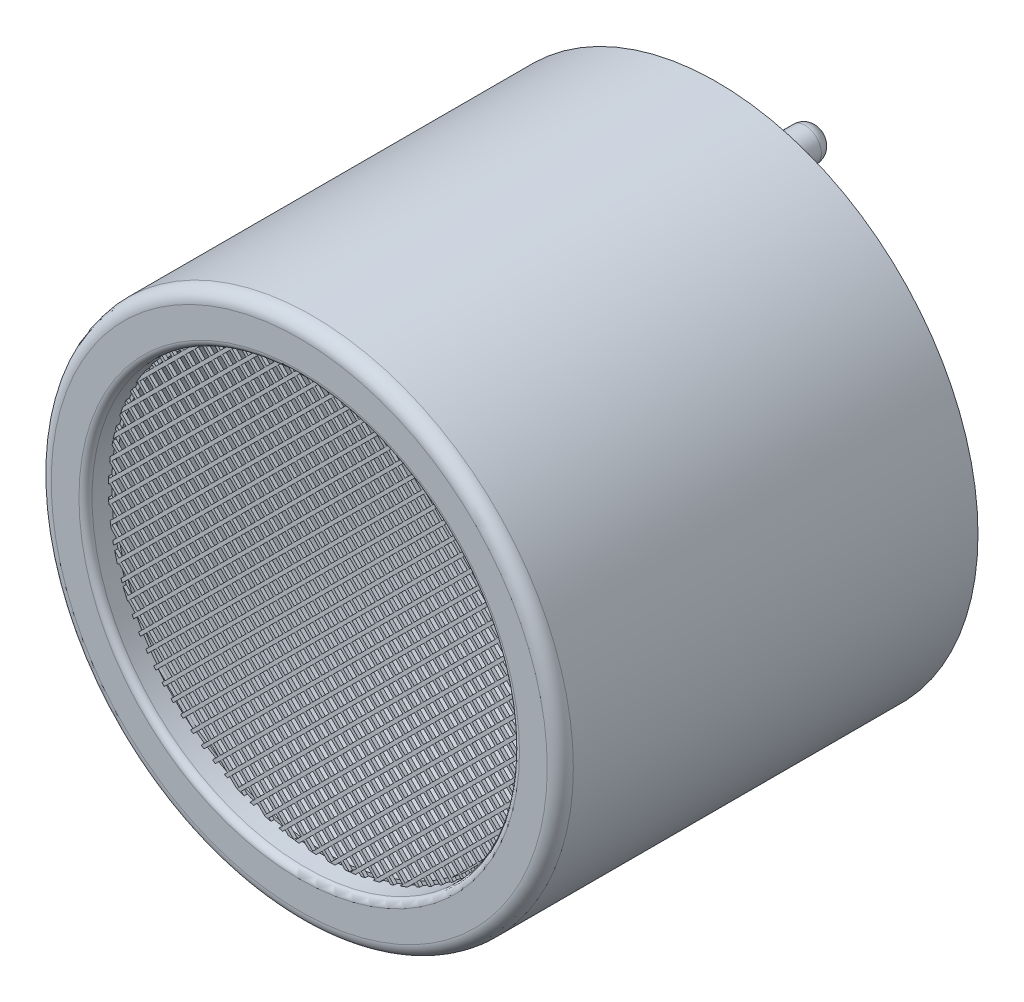
from build123d import *

# Parameters (mm, degrees)
ESQUISSE1_R             = 8
BOSS_EXTRU_1_DEPTH      = 12.8
ESQUISSE2_R             = 6.45
ENL_V_MAT_EXTRU_1_DEPTH = 10
ENL_V_MAT_EXTRU_2_DEPTH = 3.8
ESQUISSE5_R             = 0.5
BOSS_EXTRU_2_DEPTH      = 1.5
ESQUISSE6_R             = 1
BOSS_EXTRU_3_DEPTH      = 0.1
ESQUISSE7_R             = 0.5
BOSS_EXTRU_4_DEPTH      = 1.5
CONG_1_R                = 0.4
ESQUISSE8_R             = 6.55
ENL_V_MAT_EXTRU_3_DEPTH = 0.8
BOSS_EXTRU_5_DEPTH      = 0.1
BOSS_EXTRU_5_2_DEPTH    = 0.1
BOSS_EXTRU_5_3_DEPTH    = 0.1
BOSS_EXTRU_5_4_DEPTH    = 0.1
BOSS_EXTRU_5_5_DEPTH    = 0.1
BOSS_EXTRU_5_6_DEPTH    = 0.1
BOSS_EXTRU_5_7_DEPTH    = 0.1
BOSS_EXTRU_5_8_DEPTH    = 0.1
BOSS_EXTRU_5_9_DEPTH    = 0.1
BOSS_EXTRU_5_10_DEPTH   = 0.1
BOSS_EXTRU_5_11_DEPTH   = 0.1
BOSS_EXTRU_5_12_DEPTH   = 0.1
BOSS_EXTRU_5_13_DEPTH   = 0.1
BOSS_EXTRU_5_14_DEPTH   = 0.1
BOSS_EXTRU_5_15_DEPTH   = 0.1
BOSS_EXTRU_5_16_DEPTH   = 0.1
BOSS_EXTRU_5_17_DEPTH   = 0.1
BOSS_EXTRU_5_18_DEPTH   = 0.1
BOSS_EXTRU_5_19_DEPTH   = 0.1
BOSS_EXTRU_5_20_DEPTH   = 0.1
BOSS_EXTRU_5_21_DEPTH   = 0.1
BOSS_EXTRU_5_22_DEPTH   = 0.1
BOSS_EXTRU_5_23_DEPTH   = 0.1
BOSS_EXTRU_5_24_DEPTH   = 0.1
BOSS_EXTRU_5_25_DEPTH   = 0.1
BOSS_EXTRU_5_26_DEPTH   = 0.1
BOSS_EXTRU_5_27_DEPTH   = 0.1
BOSS_EXTRU_5_28_DEPTH   = 0.1
BOSS_EXTRU_5_29_DEPTH   = 0.1
BOSS_EXTRU_5_30_DEPTH   = 0.1
BOSS_EXTRU_5_31_DEPTH   = 0.1
BOSS_EXTRU_5_32_DEPTH   = 0.1
BOSS_EXTRU_5_33_DEPTH   = 0.1
BOSS_EXTRU_8_DEPTH      = 0.1
BOSS_EXTRU_8_2_DEPTH    = 0.1
BOSS_EXTRU_8_3_DEPTH    = 0.1
BOSS_EXTRU_8_4_DEPTH    = 0.1
BOSS_EXTRU_8_5_DEPTH    = 0.1
BOSS_EXTRU_8_6_DEPTH    = 0.1
BOSS_EXTRU_8_7_DEPTH    = 0.1
BOSS_EXTRU_8_8_DEPTH    = 0.1
BOSS_EXTRU_8_9_DEPTH    = 0.1
BOSS_EXTRU_8_10_DEPTH   = 0.1
BOSS_EXTRU_8_11_DEPTH   = 0.1
BOSS_EXTRU_8_12_DEPTH   = 0.1
BOSS_EXTRU_8_13_DEPTH   = 0.1
BOSS_EXTRU_8_14_DEPTH   = 0.1
BOSS_EXTRU_8_15_DEPTH   = 0.1
BOSS_EXTRU_8_16_DEPTH   = 0.1
BOSS_EXTRU_8_17_DEPTH   = 0.1
BOSS_EXTRU_8_18_DEPTH   = 0.1
BOSS_EXTRU_8_19_DEPTH   = 0.1
BOSS_EXTRU_8_20_DEPTH   = 0.1
BOSS_EXTRU_8_21_DEPTH   = 0.1
BOSS_EXTRU_8_22_DEPTH   = 0.1
BOSS_EXTRU_8_23_DEPTH   = 0.1
BOSS_EXTRU_8_24_DEPTH   = 0.1
BOSS_EXTRU_8_25_DEPTH   = 0.1
BOSS_EXTRU_8_26_DEPTH   = 0.1
BOSS_EXTRU_8_27_DEPTH   = 0.1
BOSS_EXTRU_8_28_DEPTH   = 0.1
BOSS_EXTRU_8_29_DEPTH   = 0.1
BOSS_EXTRU_8_30_DEPTH   = 0.1
BOSS_EXTRU_8_31_DEPTH   = 0.1
BOSS_EXTRU_8_32_DEPTH   = 0.1
BOSS_EXTRU_8_33_DEPTH   = 0.1
CONG_2_R                = 0.4
CONG_3_R                = 0.2


with BuildPart() as part:
    # Esquisse1 → Boss.-Extru.1 (new body)
    with BuildSketch(Plane.XY):
        Circle(ESQUISSE1_R)
    extrude(amount=-BOSS_EXTRU_1_DEPTH)

    # Esquisse2 → Enlèv. mat.-Extru.1 (cut)
    with BuildSketch(Plane.XY):
        Circle(ESQUISSE2_R)
    extrude(amount=-ENL_V_MAT_EXTRU_1_DEPTH, mode=Mode.SUBTRACT)

    # Esquisse3 → Révolution1 (revolve)
    with BuildSketch(Plane(origin=(0, 0, 0), x_dir=(1, 0, 0), z_dir=(0, 1, 0))):
        Polygon((3.75, 10), (3.75, 7.5), (3.25, 7.5), (0, 8), (0, 10), align=None)
    revolve(axis=Axis((0, 0, -8), (0, 0, -1)))

    # Esquisse4 → Enlèv. mat.-Extru.2 (cut, through all)
    with BuildSketch(Plane.XY.offset(-10)):
        with BuildLine():
            ThreePointArc((-3.558, 1.184540417), (-4.95, 0), (-3.558, -1.184540417))
            ThreePointArc((-3.558, -1.184540417), (-3.75, 0), (-3.558, 1.184540417))
        make_face()
    extrude(amount=-ENL_V_MAT_EXTRU_2_DEPTH, mode=Mode.SUBTRACT)

    # Esquisse5 → Boss.-Extru.2 (add)
    with BuildSketch(Plane(origin=(0, 0, -12.8), x_dir=(-1, 0, 0), z_dir=(0, 0, -1))):
        with Locations(Location((0, 5, 0), (0, 0, 180))):  # turned: the seam where the file's is
            Circle(ESQUISSE5_R)
        with Locations(Location((0, -5, 0), (0, 0, 180))):  # turned: the seam where the file's is
            Circle(ESQUISSE5_R)
    extrude(amount=BOSS_EXTRU_2_DEPTH)

    # Esquisse6 → Boss.-Extru.3 (add)
    with BuildSketch(Plane(origin=(0, 0, -14.3), x_dir=(-1, 0, 0), z_dir=(0, 0, -1))):
        with Locations((0, 5)):
            Circle(ESQUISSE6_R)
        with Locations((0, -5)):
            Circle(ESQUISSE6_R)
    extrude(amount=BOSS_EXTRU_3_DEPTH)

    # Esquisse7 → Boss.-Extru.4 (add)
    with BuildSketch(Plane(origin=(0, 0, -14.4), x_dir=(-1, 0, 0), z_dir=(0, 0, -1))):
        with Locations(Location((0, 5, 0), (0, 0, 180))):  # turned: the seam where the file's is
            Circle(ESQUISSE7_R)
        with Locations(Location((0, -5, 0), (0, 0, 180))):  # turned: the seam where the file's is
            Circle(ESQUISSE7_R)
    extrude(amount=BOSS_EXTRU_4_DEPTH)

    # Congé1
    cong_1_edges = [part.edges().sort_by_distance(p)[0] for p in [
        (-0.5, 5, -14.4),
        (-0.5, 5, -15.9),
        (-0.5, -5, -14.4),
        (-0.5, -5, -15.9),
    ]]
    fillet(cong_1_edges, radius=CONG_1_R)

    # Esquisse8 → Enlèv. mat.-Extru.3 (cut)
    with BuildSketch(Plane.XY):
        Circle(ESQUISSE8_R)
    extrude(amount=-ENL_V_MAT_EXTRU_3_DEPTH, mode=Mode.SUBTRACT)

    # Congé2
    cong_2_edges = [part.edges().sort_by_distance(p)[0] for p in [
        (-8, 0, 0),
    ]]
    fillet(cong_2_edges, radius=CONG_2_R)

    # Congé3
    cong_3_edges = [part.edges().sort_by_distance(p)[0] for p in [
        (-6.55, 0, 0),
    ]]
    fillet(cong_3_edges, radius=CONG_3_R)


with BuildPart() as body_2:
    # Esquisse9 → Boss.-Extru.5 (new body)
    with BuildSketch(Plane.XY.offset(-0.8)):
        Polygon((-4.631549417, -4.631549417), (4.631549417, 4.631549417), (4.701718258, 4.560301023), (-4.560301023, -4.701718258), align=None)
    extrude(amount=BOSS_EXTRU_5_DEPTH)


with BuildPart() as body_3:
    # Esquisse9 → Boss.-Extru.5 2 (new body)
    with BuildSketch(Plane.XY.offset(-0.8)):
        Polygon((-4.340064405, -4.905745709), (4.905745709, 4.340064405), (4.971586785, 4.264484124), (-4.264484124, -4.971586785), align=None)
    extrude(amount=BOSS_EXTRU_5_2_DEPTH)


with BuildPart() as body_4:
    # Esquisse9 → Boss.-Extru.5 3 (new body)
    with BuildSketch(Plane.XY.offset(-0.8)):
        Polygon((-4.031190827, -5.162557556), (5.162557556, 4.031190827), (5.224013537, 3.951225451), (-3.951225451, -5.224013537), align=None)
    extrude(amount=BOSS_EXTRU_5_3_DEPTH)


with BuildPart() as body_5:
    # Esquisse9 → Boss.-Extru.5 4 (new body)
    with BuildSketch(Plane.XY.offset(-0.8)):
        Polygon((-3.704632551, -5.401684706), (5.401684706, 3.704632551), (5.458647927, 3.620174417), (-3.620174417, -5.458647927), align=None)
    extrude(amount=BOSS_EXTRU_5_4_DEPTH)


with BuildPart() as body_6:
    # Esquisse9 → Boss.-Extru.5 5 (new body)
    with BuildSketch(Plane.XY.offset(-0.8)):
        Polygon((-3.359873206, -5.622610785), (5.622610785, 3.359873206), (5.674914693, 3.270755758), (-3.270755758, -5.674914693), align=None)
    extrude(amount=BOSS_EXTRU_5_5_DEPTH)


with BuildPart() as body_7:
    # Esquisse9 → Boss.-Extru.5 6 (new body)
    with BuildSketch(Plane.XY.offset(-0.8)):
        Polygon((-2.996146287, -5.824569291), (5.824569291, 2.996146287), (5.871977698, 2.902133338), (-2.902133338, -5.871977698), align=None)
    extrude(amount=BOSS_EXTRU_5_6_DEPTH)


with BuildPart() as body_8:
    # Esquisse9 → Boss.-Extru.5 7 (new body)
    with BuildSketch(Plane.XY.offset(-0.8)):
        Polygon((-2.612383915, -6.006492344), (6.006492344, 2.612383915), (6.048682701, 2.513152916), (-2.513152916, -6.048682701), align=None)
    extrude(amount=BOSS_EXTRU_5_7_DEPTH)


with BuildPart() as body_9:
    # Esquisse9 → Boss.-Extru.5 8 (new body)
    with BuildSketch(Plane.XY.offset(-0.8)):
        Polygon((-2.207137603, -6.166931457), (6.166931457, 2.207137603), (6.203469082, 2.102253872), (-2.102253872, -6.203469082), align=None)
    extrude(amount=BOSS_EXTRU_5_8_DEPTH)


with BuildPart() as body_10:
    # Esquisse9 → Boss.-Extru.5 9 (new body)
    with BuildSketch(Plane.XY.offset(-0.8)):
        Polygon((-1.778455644, -6.303934924), (6.303934924, 1.778455644), (6.334232693, 1.667332058), (-1.667332058, -6.334232693), align=None)
    extrude(amount=BOSS_EXTRU_5_9_DEPTH)


with BuildPart() as body_11:
    # Esquisse9 → Boss.-Extru.5 10 (new body)
    with BuildSketch(Plane.XY.offset(-0.8)):
        Polygon((-1.32368896, -6.414853664), (6.414853664, 1.32368896), (6.438106838, 1.205520778), (-1.205520778, -6.438106838), align=None)
    extrude(amount=BOSS_EXTRU_5_10_DEPTH)


with BuildPart() as body_12:
    # Esquisse9 → Boss.-Extru.5 11 (new body)
    with BuildSketch(Plane.XY.offset(-0.8)):
        Polygon((-0.839171104, -6.496021233), (6.496021233, 0.839171104), (6.511096698, 0.712825213), (-0.712825213, -6.511096698), align=None)
    extrude(amount=BOSS_EXTRU_5_11_DEPTH)


with BuildPart() as body_13:
    # Esquisse9 → Boss.-Extru.5 12 (new body)
    with BuildSketch(Plane.XY.offset(-0.8)):
        Polygon((-0.319659622, -6.542195176), (6.542195176, 0.319659622), (6.547429853, 0.183472943), (-0.183472943, -6.547429853), align=None)
    extrude(amount=BOSS_EXTRU_5_12_DEPTH)


with BuildPart() as body_14:
    # Esquisse9 → Boss.-Extru.5 13 (new body)
    with BuildSketch(Plane.XY.offset(-0.8)):
        Polygon((0.242719688, -6.545501291), (6.545501291, -0.242719688), (6.538298722, -0.391343613), (0.391343613, -6.538298722), align=None)
    extrude(amount=BOSS_EXTRU_5_13_DEPTH)


with BuildPart() as body_15:
    # Esquisse9 → Boss.-Extru.5 14 (new body)
    with BuildSketch(Plane.XY.offset(-0.8)):
        Polygon((0.860703009, -6.493203395), (6.493203395, -0.860703009), (6.469109349, -1.026218411), (1.026218411, -6.469109349), align=None)
    extrude(amount=BOSS_EXTRU_5_14_DEPTH)


with BuildPart() as body_16:
    # Esquisse9 → Boss.-Extru.5 15 (new body)
    with BuildSketch(Plane.XY.offset(-0.8)):
        Polygon((1.557449912, -6.362141917), (6.362141917, -1.557449912), (6.312231074, -1.748782111), (1.748782111, -6.312231074), align=None)
    extrude(amount=BOSS_EXTRU_5_15_DEPTH)


with BuildPart() as body_17:
    # Esquisse9 → Boss.-Extru.5 16 (new body)
    with BuildSketch(Plane.XY.offset(-0.8)):
        Polygon((2.384879901, -6.100397352), (6.100397352, -2.384879901), (6.000437854, -2.626260756), (2.626260756, -6.000437854), align=None)
    extrude(amount=BOSS_EXTRU_5_16_DEPTH)


with BuildPart() as body_18:
    # Esquisse9 → Boss.-Extru.5 17 (new body)
    with BuildSketch(Plane.XY.offset(-0.8)):
        with BuildLine():
            Line((3.958675687, -5.092286991), (5.092286991, -3.958675687))
            ThreePointArc((5.092286991, -3.958675687), (4.560838739, -4.560838739), (3.958675687, -5.092286991))
        make_face()
    extrude(amount=BOSS_EXTRU_5_17_DEPTH)


with BuildPart() as body_19:
    # Esquisse9 → Boss.-Extru.5 18 (new body)
    with BuildSketch(Plane.XY.offset(-0.8)):
        Polygon((-4.838820915, -4.414556846), (4.414556846, 4.838820915), (4.340062218, 4.905747643), (-4.905747643, -4.340062218), align=None)
    extrude(amount=BOSS_EXTRU_5_18_DEPTH)


with BuildPart() as body_20:
    # Esquisse9 → Boss.-Extru.5 19 (new body)
    with BuildSketch(Plane.XY.offset(-0.8)):
        Polygon((-5.099999177, -4.110049683), (4.110049683, 5.099999177), (4.031188513, 5.162559363), (-5.162559363, -4.031188513), align=None)
    extrude(amount=BOSS_EXTRU_5_19_DEPTH)


with BuildPart() as body_21:
    # Esquisse9 → Boss.-Extru.5 20 (new body)
    with BuildSketch(Plane.XY.offset(-0.8)):
        Polygon((-5.343586836, -3.787951917), (3.787951917, 5.343586836), (3.704630107, 5.401686382), (-5.401686382, -3.704630107), align=None)
    extrude(amount=BOSS_EXTRU_5_20_DEPTH)


with BuildPart() as body_22:
    # Esquisse9 → Boss.-Extru.5 21 (new body)
    with BuildSketch(Plane.XY.offset(-0.8)):
        Polygon((-5.569124434, -3.44780409), (3.44780409, 5.569124434), (3.359870627, 5.622612326), (-5.622612326, -3.359870627), align=None)
    extrude(amount=BOSS_EXTRU_5_21_DEPTH)


with BuildPart() as body_23:
    # Esquisse9 → Boss.-Extru.5 22 (new body)
    with BuildSketch(Plane.XY.offset(-0.8)):
        Polygon((-5.775911936, -3.088906167), (3.088906167, 5.775911936), (2.996143566, 5.824570691), (-5.824570691, -2.996143566), align=None)
    extrude(amount=BOSS_EXTRU_5_22_DEPTH)


with BuildPart() as body_24:
    # Esquisse9 → Boss.-Extru.5 23 (new body)
    with BuildSketch(Plane.XY.offset(-0.8)):
        Polygon((-5.962962942, -2.710271749), (2.710271749, 5.962962942), (2.612381043, 6.006493593), (-6.006493593, -2.612381043), align=None)
    extrude(amount=BOSS_EXTRU_5_23_DEPTH)


with BuildPart() as body_25:
    # Esquisse9 → Boss.-Extru.5 24 (new body)
    with BuildSketch(Plane.XY.offset(-0.8)):
        Polygon((-6.128933562, -2.310556944), (2.310556944, 6.128933562), (2.207134569, 6.166932543), (-6.166932543, -2.207134569), align=None)
    extrude(amount=BOSS_EXTRU_5_24_DEPTH)


with BuildPart() as body_26:
    # Esquisse9 → Boss.-Extru.5 25 (new body)
    with BuildSketch(Plane.XY.offset(-0.8)):
        Polygon((-6.272012639, -1.887950596), (1.887950596, 6.272012639), (1.778452431, 6.30393583), (-6.30393583, -1.778452431), align=None)
    extrude(amount=BOSS_EXTRU_5_25_DEPTH)


with BuildPart() as body_27:
    # Esquisse9 → Boss.-Extru.5 26 (new body)
    with BuildSketch(Plane.XY.offset(-0.8)):
        Polygon((-6.389749211, -1.440001743), (1.440001743, 6.389749211), (1.323685545, 6.414854369), (-6.414854369, -1.323685545), align=None)
    extrude(amount=BOSS_EXTRU_5_26_DEPTH)


with BuildPart() as body_28:
    # Esquisse9 → Boss.-Extru.5 27 (new body)
    with BuildSketch(Plane.XY.offset(-0.8)):
        Polygon((-6.478771405, -0.963338511), (0.963338511, 6.478771405), (0.839167455, 6.496021704), (-6.496021704, -0.839167455), align=None)
    extrude(amount=BOSS_EXTRU_5_27_DEPTH)


with BuildPart() as body_29:
    # Esquisse9 → Boss.-Extru.5 28 (new body)
    with BuildSketch(Plane.XY.offset(-0.8)):
        Polygon((-6.534303569, -0.453185251), (0.453185251, 6.534303569), (0.319655694, 6.542195368), (-6.542195368, -0.319655694), align=None)
    extrude(amount=BOSS_EXTRU_5_28_DEPTH)


with BuildPart() as body_30:
    # Esquisse9 → Boss.-Extru.5 29 (new body)
    with BuildSketch(Plane.XY.offset(-0.8)):
        Polygon((-6.549273847, 0.097529896), (-0.097529896, 6.549273847), (-0.242723967, 6.545501133), (-6.545501133, 0.242723967), align=None)
    extrude(amount=BOSS_EXTRU_5_29_DEPTH)


with BuildPart() as body_31:
    # Esquisse9 → Boss.-Extru.5 30 (new body)
    with BuildSketch(Plane.XY.offset(-0.8)):
        Polygon((-6.512487864, 0.700001304), (-0.700001304, 6.512487864), (-0.860707759, 6.493202765), (-6.493202765, 0.860707759), align=None)
    extrude(amount=BOSS_EXTRU_5_30_DEPTH)


with BuildPart() as body_32:
    # Esquisse9 → Boss.-Extru.5 31 (new body)
    with BuildSketch(Plane.XY.offset(-0.8)):
        Polygon((-6.404291066, 1.373883527), (-1.373883527, 6.404291066), (-1.557455368, 6.362140581), (-6.362140581, 1.557455368), align=None)
    extrude(amount=BOSS_EXTRU_5_31_DEPTH)


with BuildPart() as body_33:
    # Esquisse9 → Boss.-Extru.5 32 (new body)
    with BuildSketch(Plane.XY.offset(-0.8)):
        Polygon((-6.183459278, 2.16040074), (-2.16040074, 6.183459278), (-2.384886667, 6.100394707), (-6.100394707, 2.384886667), align=None)
    extrude(amount=BOSS_EXTRU_5_32_DEPTH)


with BuildPart() as body_34:
    # Esquisse9 → Boss.-Extru.5 33 (new body)
    with BuildSketch(Plane.XY.offset(-0.8)):
        Polygon((-3.187393536, 5.722151907), (-5.722151907, 3.187393536), (-5.511003567, 3.539963232), (-3.539963232, 5.511003567), align=None)
    extrude(amount=BOSS_EXTRU_5_33_DEPTH)


with BuildPart() as body_35:
    # Esquisse11 → Boss.-Extru.8 (new body)
    with BuildSketch(Plane(origin=(0, 0, -0.8), x_dir=(-1, 0, 0), z_dir=(0, 0, -1))):
        Polygon((-4.631549417, -4.631549417), (4.631549417, 4.631549417), (4.701718258, 4.560301023), (-4.560301023, -4.701718258), align=None)
    extrude(amount=-BOSS_EXTRU_8_DEPTH)


with BuildPart() as body_36:
    # Esquisse11 → Boss.-Extru.8 2 (new body)
    with BuildSketch(Plane(origin=(0, 0, -0.8), x_dir=(-1, 0, 0), z_dir=(0, 0, -1))):
        Polygon((-4.340064405, -4.905745709), (4.905745709, 4.340064405), (4.971586785, 4.264484124), (-4.264484124, -4.971586785), align=None)
    extrude(amount=-BOSS_EXTRU_8_2_DEPTH)


with BuildPart() as body_37:
    # Esquisse11 → Boss.-Extru.8 3 (new body)
    with BuildSketch(Plane(origin=(0, 0, -0.8), x_dir=(-1, 0, 0), z_dir=(0, 0, -1))):
        Polygon((-4.031190827, -5.162557556), (5.162557556, 4.031190827), (5.224013537, 3.951225451), (-3.951225451, -5.224013537), align=None)
    extrude(amount=-BOSS_EXTRU_8_3_DEPTH)


with BuildPart() as body_38:
    # Esquisse11 → Boss.-Extru.8 4 (new body)
    with BuildSketch(Plane(origin=(0, 0, -0.8), x_dir=(-1, 0, 0), z_dir=(0, 0, -1))):
        Polygon((-3.704632551, -5.401684706), (5.401684706, 3.704632551), (5.458647927, 3.620174417), (-3.620174417, -5.458647927), align=None)
    extrude(amount=-BOSS_EXTRU_8_4_DEPTH)


with BuildPart() as body_39:
    # Esquisse11 → Boss.-Extru.8 5 (new body)
    with BuildSketch(Plane(origin=(0, 0, -0.8), x_dir=(-1, 0, 0), z_dir=(0, 0, -1))):
        Polygon((-3.359873206, -5.622610785), (5.622610785, 3.359873206), (5.674914693, 3.270755758), (-3.270755758, -5.674914693), align=None)
    extrude(amount=-BOSS_EXTRU_8_5_DEPTH)


with BuildPart() as body_40:
    # Esquisse11 → Boss.-Extru.8 6 (new body)
    with BuildSketch(Plane(origin=(0, 0, -0.8), x_dir=(-1, 0, 0), z_dir=(0, 0, -1))):
        Polygon((-2.996146287, -5.824569291), (5.824569291, 2.996146287), (5.871977698, 2.902133338), (-2.902133338, -5.871977698), align=None)
    extrude(amount=-BOSS_EXTRU_8_6_DEPTH)


with BuildPart() as body_41:
    # Esquisse11 → Boss.-Extru.8 7 (new body)
    with BuildSketch(Plane(origin=(0, 0, -0.8), x_dir=(-1, 0, 0), z_dir=(0, 0, -1))):
        Polygon((-2.612383915, -6.006492344), (6.006492344, 2.612383915), (6.048682701, 2.513152916), (-2.513152916, -6.048682701), align=None)
    extrude(amount=-BOSS_EXTRU_8_7_DEPTH)


with BuildPart() as body_42:
    # Esquisse11 → Boss.-Extru.8 8 (new body)
    with BuildSketch(Plane(origin=(0, 0, -0.8), x_dir=(-1, 0, 0), z_dir=(0, 0, -1))):
        Polygon((-2.207137603, -6.166931457), (6.166931457, 2.207137603), (6.203469082, 2.102253872), (-2.102253872, -6.203469082), align=None)
    extrude(amount=-BOSS_EXTRU_8_8_DEPTH)


with BuildPart() as body_43:
    # Esquisse11 → Boss.-Extru.8 9 (new body)
    with BuildSketch(Plane(origin=(0, 0, -0.8), x_dir=(-1, 0, 0), z_dir=(0, 0, -1))):
        Polygon((-1.778455644, -6.303934924), (6.303934924, 1.778455644), (6.334232693, 1.667332058), (-1.667332058, -6.334232693), align=None)
    extrude(amount=-BOSS_EXTRU_8_9_DEPTH)


with BuildPart() as body_44:
    # Esquisse11 → Boss.-Extru.8 10 (new body)
    with BuildSketch(Plane(origin=(0, 0, -0.8), x_dir=(-1, 0, 0), z_dir=(0, 0, -1))):
        Polygon((-1.32368896, -6.414853664), (6.414853664, 1.32368896), (6.438106838, 1.205520778), (-1.205520778, -6.438106838), align=None)
    extrude(amount=-BOSS_EXTRU_8_10_DEPTH)


with BuildPart() as body_45:
    # Esquisse11 → Boss.-Extru.8 11 (new body)
    with BuildSketch(Plane(origin=(0, 0, -0.8), x_dir=(-1, 0, 0), z_dir=(0, 0, -1))):
        Polygon((-0.839171104, -6.496021233), (6.496021233, 0.839171104), (6.511096698, 0.712825213), (-0.712825213, -6.511096698), align=None)
    extrude(amount=-BOSS_EXTRU_8_11_DEPTH)


with BuildPart() as body_46:
    # Esquisse11 → Boss.-Extru.8 12 (new body)
    with BuildSketch(Plane(origin=(0, 0, -0.8), x_dir=(-1, 0, 0), z_dir=(0, 0, -1))):
        Polygon((-0.319659622, -6.542195176), (6.542195176, 0.319659622), (6.547429853, 0.183472943), (-0.183472943, -6.547429853), align=None)
    extrude(amount=-BOSS_EXTRU_8_12_DEPTH)


with BuildPart() as body_47:
    # Esquisse11 → Boss.-Extru.8 13 (new body)
    with BuildSketch(Plane(origin=(0, 0, -0.8), x_dir=(-1, 0, 0), z_dir=(0, 0, -1))):
        Polygon((0.242719688, -6.545501291), (6.545501291, -0.242719688), (6.538298722, -0.391343613), (0.391343613, -6.538298722), align=None)
    extrude(amount=-BOSS_EXTRU_8_13_DEPTH)


with BuildPart() as body_48:
    # Esquisse11 → Boss.-Extru.8 14 (new body)
    with BuildSketch(Plane(origin=(0, 0, -0.8), x_dir=(-1, 0, 0), z_dir=(0, 0, -1))):
        Polygon((0.860703009, -6.493203395), (6.493203395, -0.860703009), (6.469109349, -1.026218411), (1.026218411, -6.469109349), align=None)
    extrude(amount=-BOSS_EXTRU_8_14_DEPTH)


with BuildPart() as body_49:
    # Esquisse11 → Boss.-Extru.8 15 (new body)
    with BuildSketch(Plane(origin=(0, 0, -0.8), x_dir=(-1, 0, 0), z_dir=(0, 0, -1))):
        Polygon((1.557449912, -6.362141917), (6.362141917, -1.557449912), (6.312231074, -1.748782111), (1.748782111, -6.312231074), align=None)
    extrude(amount=-BOSS_EXTRU_8_15_DEPTH)


with BuildPart() as body_50:
    # Esquisse11 → Boss.-Extru.8 16 (new body)
    with BuildSketch(Plane(origin=(0, 0, -0.8), x_dir=(-1, 0, 0), z_dir=(0, 0, -1))):
        Polygon((2.384879901, -6.100397352), (6.100397352, -2.384879901), (6.000437854, -2.626260756), (2.626260756, -6.000437854), align=None)
    extrude(amount=-BOSS_EXTRU_8_16_DEPTH)


with BuildPart() as body_51:
    # Esquisse11 → Boss.-Extru.8 17 (new body)
    with BuildSketch(Plane(origin=(0, 0, -0.8), x_dir=(-1, 0, 0), z_dir=(0, 0, -1))):
        with BuildLine():
            Line((3.958675687, -5.092286991), (5.092286991, -3.958675687))
            ThreePointArc((5.092286991, -3.958675687), (4.560838739, -4.560838739), (3.958675687, -5.092286991))
        make_face()
    extrude(amount=-BOSS_EXTRU_8_17_DEPTH)


with BuildPart() as body_52:
    # Esquisse11 → Boss.-Extru.8 18 (new body)
    with BuildSketch(Plane(origin=(0, 0, -0.8), x_dir=(-1, 0, 0), z_dir=(0, 0, -1))):
        Polygon((-4.838820915, -4.414556846), (4.414556846, 4.838820915), (4.340062218, 4.905747643), (-4.905747643, -4.340062218), align=None)
    extrude(amount=-BOSS_EXTRU_8_18_DEPTH)


with BuildPart() as body_53:
    # Esquisse11 → Boss.-Extru.8 19 (new body)
    with BuildSketch(Plane(origin=(0, 0, -0.8), x_dir=(-1, 0, 0), z_dir=(0, 0, -1))):
        Polygon((-5.099999177, -4.110049683), (4.110049683, 5.099999177), (4.031188513, 5.162559363), (-5.162559363, -4.031188513), align=None)
    extrude(amount=-BOSS_EXTRU_8_19_DEPTH)


with BuildPart() as body_54:
    # Esquisse11 → Boss.-Extru.8 20 (new body)
    with BuildSketch(Plane(origin=(0, 0, -0.8), x_dir=(-1, 0, 0), z_dir=(0, 0, -1))):
        Polygon((-5.343586836, -3.787951917), (3.787951917, 5.343586836), (3.704630107, 5.401686382), (-5.401686382, -3.704630107), align=None)
    extrude(amount=-BOSS_EXTRU_8_20_DEPTH)


with BuildPart() as body_55:
    # Esquisse11 → Boss.-Extru.8 21 (new body)
    with BuildSketch(Plane(origin=(0, 0, -0.8), x_dir=(-1, 0, 0), z_dir=(0, 0, -1))):
        Polygon((-5.569124434, -3.44780409), (3.44780409, 5.569124434), (3.359870627, 5.622612326), (-5.622612326, -3.359870627), align=None)
    extrude(amount=-BOSS_EXTRU_8_21_DEPTH)


with BuildPart() as body_56:
    # Esquisse11 → Boss.-Extru.8 22 (new body)
    with BuildSketch(Plane(origin=(0, 0, -0.8), x_dir=(-1, 0, 0), z_dir=(0, 0, -1))):
        Polygon((-5.775911936, -3.088906167), (3.088906167, 5.775911936), (2.996143566, 5.824570691), (-5.824570691, -2.996143566), align=None)
    extrude(amount=-BOSS_EXTRU_8_22_DEPTH)


with BuildPart() as body_57:
    # Esquisse11 → Boss.-Extru.8 23 (new body)
    with BuildSketch(Plane(origin=(0, 0, -0.8), x_dir=(-1, 0, 0), z_dir=(0, 0, -1))):
        Polygon((-5.962962942, -2.710271749), (2.710271749, 5.962962942), (2.612381043, 6.006493593), (-6.006493593, -2.612381043), align=None)
    extrude(amount=-BOSS_EXTRU_8_23_DEPTH)


with BuildPart() as body_58:
    # Esquisse11 → Boss.-Extru.8 24 (new body)
    with BuildSketch(Plane(origin=(0, 0, -0.8), x_dir=(-1, 0, 0), z_dir=(0, 0, -1))):
        Polygon((-6.128933562, -2.310556944), (2.310556944, 6.128933562), (2.207134569, 6.166932543), (-6.166932543, -2.207134569), align=None)
    extrude(amount=-BOSS_EXTRU_8_24_DEPTH)


with BuildPart() as body_59:
    # Esquisse11 → Boss.-Extru.8 25 (new body)
    with BuildSketch(Plane(origin=(0, 0, -0.8), x_dir=(-1, 0, 0), z_dir=(0, 0, -1))):
        Polygon((-6.272012639, -1.887950596), (1.887950596, 6.272012639), (1.778452431, 6.30393583), (-6.30393583, -1.778452431), align=None)
    extrude(amount=-BOSS_EXTRU_8_25_DEPTH)


with BuildPart() as body_60:
    # Esquisse11 → Boss.-Extru.8 26 (new body)
    with BuildSketch(Plane(origin=(0, 0, -0.8), x_dir=(-1, 0, 0), z_dir=(0, 0, -1))):
        Polygon((-6.389749211, -1.440001743), (1.440001743, 6.389749211), (1.323685545, 6.414854369), (-6.414854369, -1.323685545), align=None)
    extrude(amount=-BOSS_EXTRU_8_26_DEPTH)


with BuildPart() as body_61:
    # Esquisse11 → Boss.-Extru.8 27 (new body)
    with BuildSketch(Plane(origin=(0, 0, -0.8), x_dir=(-1, 0, 0), z_dir=(0, 0, -1))):
        Polygon((-6.478771405, -0.963338511), (0.963338511, 6.478771405), (0.839167455, 6.496021704), (-6.496021704, -0.839167455), align=None)
    extrude(amount=-BOSS_EXTRU_8_27_DEPTH)


with BuildPart() as body_62:
    # Esquisse11 → Boss.-Extru.8 28 (new body)
    with BuildSketch(Plane(origin=(0, 0, -0.8), x_dir=(-1, 0, 0), z_dir=(0, 0, -1))):
        Polygon((-6.534303569, -0.453185251), (0.453185251, 6.534303569), (0.319655694, 6.542195368), (-6.542195368, -0.319655694), align=None)
    extrude(amount=-BOSS_EXTRU_8_28_DEPTH)


with BuildPart() as body_63:
    # Esquisse11 → Boss.-Extru.8 29 (new body)
    with BuildSketch(Plane(origin=(0, 0, -0.8), x_dir=(-1, 0, 0), z_dir=(0, 0, -1))):
        Polygon((-6.549273847, 0.097529896), (-0.097529896, 6.549273847), (-0.242723967, 6.545501133), (-6.545501133, 0.242723967), align=None)
    extrude(amount=-BOSS_EXTRU_8_29_DEPTH)


with BuildPart() as body_64:
    # Esquisse11 → Boss.-Extru.8 30 (new body)
    with BuildSketch(Plane(origin=(0, 0, -0.8), x_dir=(-1, 0, 0), z_dir=(0, 0, -1))):
        Polygon((-6.512487864, 0.700001304), (-0.700001304, 6.512487864), (-0.860707759, 6.493202765), (-6.493202765, 0.860707759), align=None)
    extrude(amount=-BOSS_EXTRU_8_30_DEPTH)


with BuildPart() as body_65:
    # Esquisse11 → Boss.-Extru.8 31 (new body)
    with BuildSketch(Plane(origin=(0, 0, -0.8), x_dir=(-1, 0, 0), z_dir=(0, 0, -1))):
        Polygon((-6.404291066, 1.373883527), (-1.373883527, 6.404291066), (-1.557455368, 6.362140581), (-6.362140581, 1.557455368), align=None)
    extrude(amount=-BOSS_EXTRU_8_31_DEPTH)


with BuildPart() as body_66:
    # Esquisse11 → Boss.-Extru.8 32 (new body)
    with BuildSketch(Plane(origin=(0, 0, -0.8), x_dir=(-1, 0, 0), z_dir=(0, 0, -1))):
        Polygon((-6.183459278, 2.16040074), (-2.16040074, 6.183459278), (-2.384886667, 6.100394707), (-6.100394707, 2.384886667), align=None)
    extrude(amount=-BOSS_EXTRU_8_32_DEPTH)


with BuildPart() as body_67:
    # Esquisse11 → Boss.-Extru.8 33 (new body)
    with BuildSketch(Plane(origin=(0, 0, -0.8), x_dir=(-1, 0, 0), z_dir=(0, 0, -1))):
        Polygon((-3.187393536, 5.722151907), (-5.722151907, 3.187393536), (-5.511003567, 3.539963232), (-3.539963232, 5.511003567), align=None)
    extrude(amount=-BOSS_EXTRU_8_33_DEPTH)


solid = Compound([part.part, body_2.part, body_3.part, body_4.part, body_5.part, body_6.part, body_7.part, body_8.part, body_9.part, body_10.part, body_11.part, body_12.part, body_13.part, body_14.part, body_15.part, body_16.part, body_17.part, body_18.part, body_19.part, body_20.part, body_21.part, body_22.part, body_23.part, body_24.part, body_25.part, body_26.part, body_27.part, body_28.part, body_29.part, body_30.part, body_31.part, body_32.part, body_33.part, body_34.part, body_35.part, body_36.part, body_37.part, body_38.part, body_39.part, body_40.part, body_41.part, body_42.part, body_43.part, body_44.part, body_45.part, body_46.part, body_47.part, body_48.part, body_49.part, body_50.part, body_51.part, body_52.part, body_53.part, body_54.part, body_55.part, body_56.part, body_57.part, body_58.part, body_59.part, body_60.part, body_61.part, body_62.part, body_63.part, body_64.part, body_65.part, body_66.part, body_67.part])
